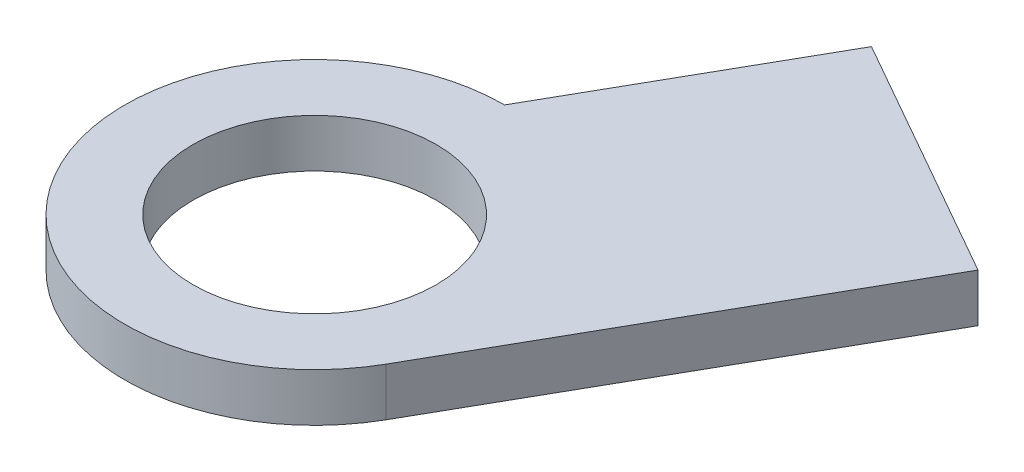
from build123d import *

# Parameters (mm, degrees)
SKETCH1_R           = 12.5
BOSS_EXTRUDE1_DEPTH = 17.6
SKETCH2_R           = 5.5
CUT_EXTRUDE1_DEPTH  = 50.8
SKETCH3_R           = 8
CUT_EXTRUDE3_DEPTH  = 15.6
BOSS_EXTRUDE2_DEPTH = 17.6
SKETCH6_R           = 8
SKETCH6_R_2         = 5.5
CUT_EXTRUDE5_DEPTH  = 14.425


with BuildPart() as part:
    # Sketch1 → Boss-Extrude1 (new body)
    with BuildSketch(Plane(origin=(0, 0, 0), x_dir=(1, 0, 0), z_dir=(0, 1, 0))):
        with Locations(Location((0, 0, 0), (0, 0, 270))):
            Circle(SKETCH1_R)
    extrude(amount=BOSS_EXTRUDE1_DEPTH)

    # Sketch2 → Cut-Extrude1 (cut)
    with BuildSketch(Plane(origin=(0, 17.6, 0), x_dir=(1, 0, 0), z_dir=(0, 1, 0))):
        with Locations(Location((0, 0, 0), (0, 0, 270))):
            Circle(SKETCH2_R)
    extrude(amount=-CUT_EXTRUDE1_DEPTH, mode=Mode.SUBTRACT)

    # Sketch3 → Cut-Extrude3 (cut)
    with BuildSketch(Plane(origin=(0, 17.6, 0), x_dir=(1, 0, 0), z_dir=(0, 1, 0))):
        with Locations(Location((0, 0, 0), (0, 0, 270))):
            Circle(SKETCH3_R)
    extrude(amount=-CUT_EXTRUDE3_DEPTH, mode=Mode.SUBTRACT)

    # Sketch5 → Boss-Extrude2 (add, through all)
    with BuildSketch(Plane(origin=(0, 17.6, 0), x_dir=(1, 0, 0), z_dir=(0, 1, 0))):
        with BuildLine():
            ThreePointArc((12.5, 0), (12.085103338, -3.193787298), (10.867955631, -6.175559927))
            Line((10.867955631, -6.175559927), (24.985285623, 18.668586645))
            Line((24.985285623, 18.668586645), (8.74807309, 27.895149805))
            Line((8.74807309, 27.895149805), (0, 12.5))
            ThreePointArc((0, 12.5), (8.838834765, 8.838834765), (12.5, 0))
        make_face()
    extrude(amount=-BOSS_EXTRUDE2_DEPTH)

    # Sketch6 → Cut-Extrude5 (cut)
    with BuildSketch(Plane.XZ):
        with BuildLine():
            Line((24.985285623, -18.668586645), (10.867955631, 6.175559927))
            ThreePointArc((10.867955631, 6.175559927), (-10.803807178, 6.287109865), (0, -12.5))
            Line((0, -12.5), (8.74807309, -27.895149805))
            Line((8.74807309, -27.895149805), (24.985285623, -18.668586645))
        make_face()
        with Locations(Location((0, 0, 0), (0, 0, 90))):
            Circle(SKETCH6_R, mode=Mode.SUBTRACT)
        with Locations(Location((0, 0, 0), (0, 0, 90))):
            Circle(SKETCH6_R)
        Circle(SKETCH6_R_2, mode=Mode.SUBTRACT)
    extrude(amount=-CUT_EXTRUDE5_DEPTH, mode=Mode.SUBTRACT)


solid = part.part
